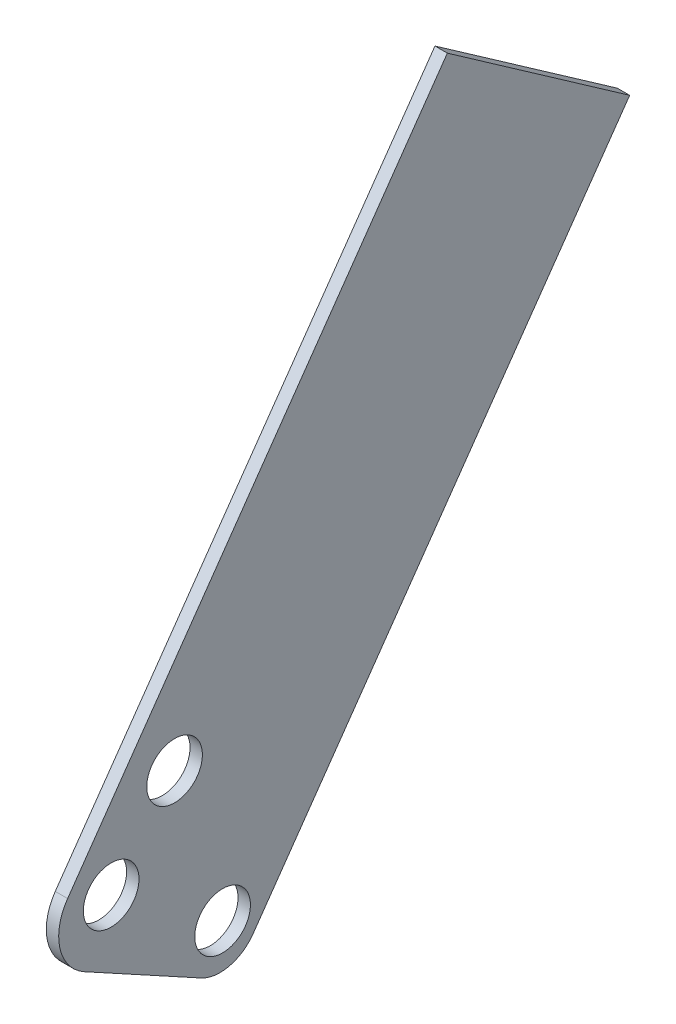
from build123d import *

# Parameters (mm, degrees)
BOSS_EXTRUDE2_DEPTH      = 3.175
BOSS_EXTRUDE2_DEPTH_BACK = 3.175
SKETCH1_R                = 14.2875


with BuildPart() as part:
    # Sketch1 → Boss-Extrude2 (new, two sides: drawn at the far end of the back side and taken through both)
    with BuildSketch(Plane(origin=(0, 0, 0), x_dir=(0, 0, -1), z_dir=(1, 0, 0)).offset(-BOSS_EXTRUDE2_DEPTH_BACK)):
        with BuildLine():
            Line((10.594785966, 15.13092246), (203.963780766, 291.290466949))
            Line((203.963780766, 291.290466949), (110.334702104, 356.850253624))
            Line((110.334702104, 356.850253624), (-84.6362425, 78.402887714))
            ThreePointArc((-84.6362425, 78.402887714), (-88.561708566, 58.046841565), (-76.011825816, 41.54598275))
            Line((-76.011825816, 41.54598275), (-16.208376106, 8.859054586))
            ThreePointArc((-16.208376106, 8.859054586), (-1.608360556, 6.873414672), (10.594785966, 15.13092246))
        make_face()
        with Locations((-62.285836902, 68.806748098)):
            Circle(SKETCH1_R, mode=Mode.SUBTRACT)
        with Locations((-5.068066609, 28.742434019)):
            Circle(SKETCH1_R, mode=Mode.SUBTRACT)
        with Locations((-29.716861807, 107.792666854)):
            Circle(SKETCH1_R, mode=Mode.SUBTRACT)
    extrude(amount=BOSS_EXTRUDE2_DEPTH + BOSS_EXTRUDE2_DEPTH_BACK)


solid = part.part
